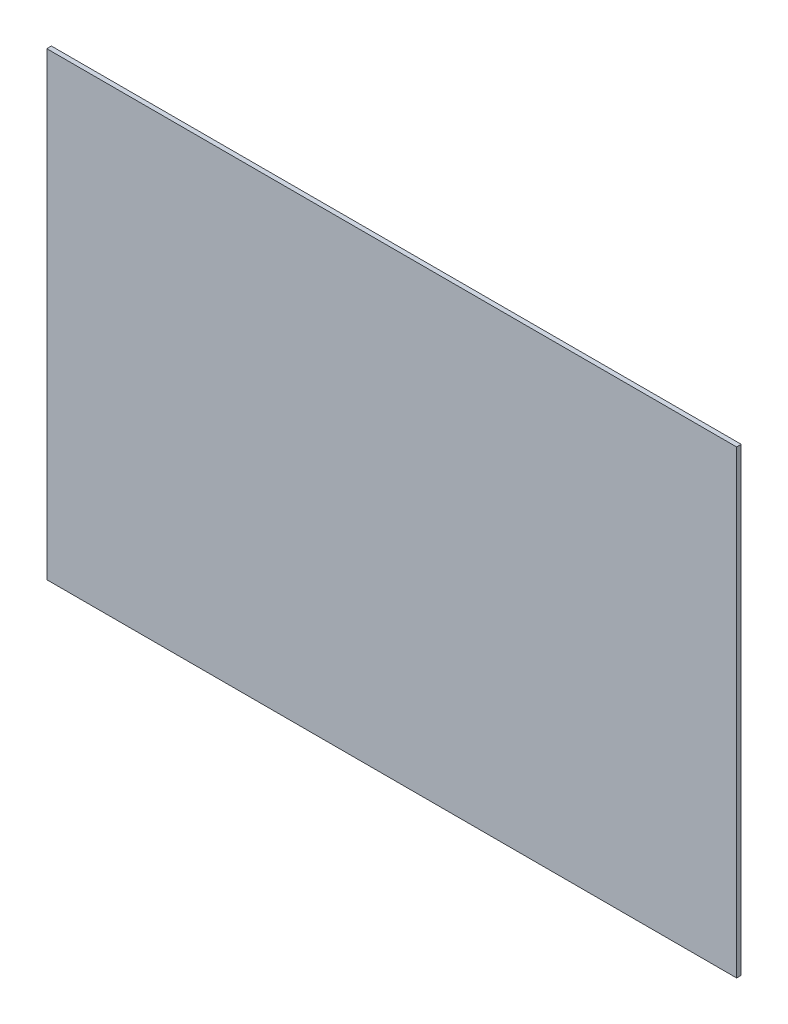
from build123d import *

# Parameters (mm, degrees)
SKETCH1_W           = 300
SKETCH1_H           = 200
BOSS_EXTRUDE1_DEPTH = 2


with BuildPart() as part:
    # Sketch1 → Boss-Extrude1 (new body)
    with BuildSketch(Plane.XY):
        Rectangle(SKETCH1_W, SKETCH1_H)
    extrude(amount=BOSS_EXTRUDE1_DEPTH)


solid = part.part
